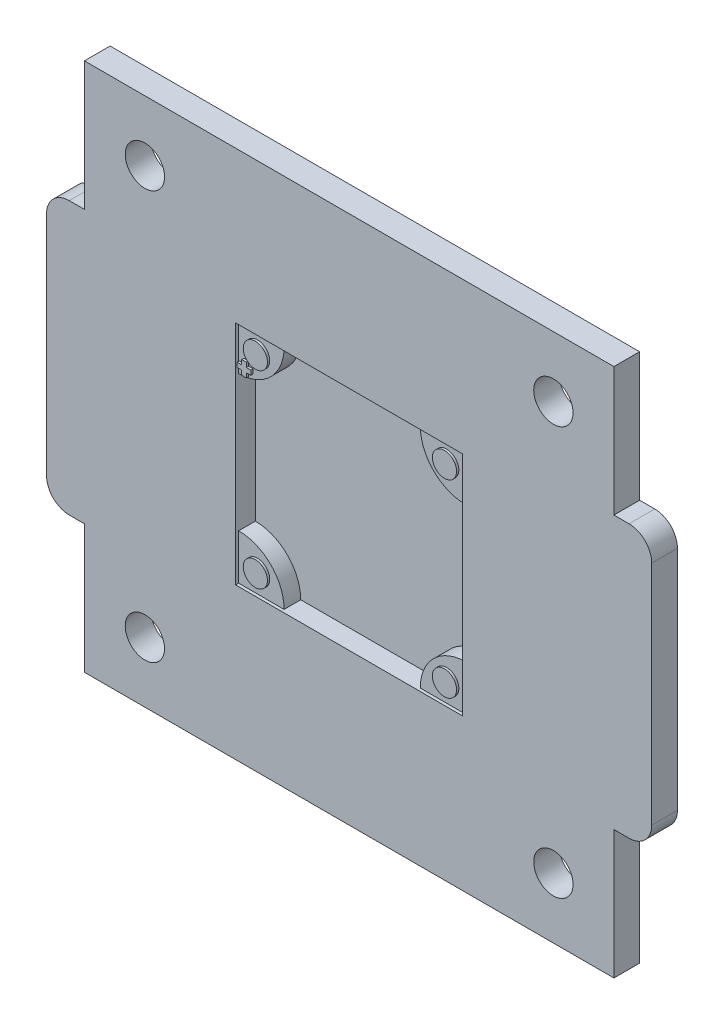
from build123d import *

# Parameters (mm, degrees)
SKETCH_1_W          = 70
SKETCH_1_H          = 70
EXTRUDE_1_DEPTH     = 3.4
SKETCH_2_W          = 30
SKETCH_2_H          = 30
CUT_EXTRUDE_1_DEPTH = 2.6
SKETCH_3_R          = 2.6
CUT_EXTRUDE_2_DEPTH = 4.4
EXTRUDE_2_DEPTH     = 3
SKETCH_6_R          = 1.6
EXTRUDE_3_DEPTH     = 0.3


with BuildPart() as part:
    # 草图1 → 凸台-拉伸1 (new body)
    with BuildSketch(Plane.XY):
        with BuildLine():
            Line((-2, 17), (0, 17))
            Line((0, 17), (0, 53))
            Line((0, 53), (-2, 53))
            ThreePointArc((-2, 53), (-4.121320344, 52.121320344), (-5, 50))
            Line((-5, 50), (-5, 20))
            ThreePointArc((-5, 20), (-4.121320344, 17.878679656), (-2, 17))
        make_face()
        with Locations((35, 35)):
            Rectangle(SKETCH_1_W, SKETCH_1_H)
        with BuildLine():
            Line((70, 53), (70, 17))
            Line((70, 17), (72, 17))
            ThreePointArc((72, 17), (74.121320344, 17.878679656), (75, 20))
            Line((75, 20), (75, 50))
            ThreePointArc((75, 50), (74.121320344, 52.121320344), (72, 53))
            Line((72, 53), (70, 53))
        make_face()
    extrude(amount=EXTRUDE_1_DEPTH)

    # 草图2 → 切除-拉伸1 (cut)
    with BuildSketch(Plane.XY.offset(3.4)):
        with Locations((35, 35)):
            Rectangle(SKETCH_2_W, SKETCH_2_H)
    extrude(amount=-CUT_EXTRUDE_1_DEPTH, mode=Mode.SUBTRACT)

    # 草图3 → 切除-拉伸2 (cut, through all)
    with BuildSketch(Plane.XY.offset(3.4)):
        with Locations((8, 62)):
            Circle(SKETCH_3_R)
        with Locations((62, 62)):
            Circle(SKETCH_3_R)
        with Locations((8, 8)):
            Circle(SKETCH_3_R)
        with Locations((62, 8)):
            Circle(SKETCH_3_R)
    extrude(amount=-CUT_EXTRUDE_2_DEPTH, mode=Mode.SUBTRACT)

    # 草图4 → 凸台-拉伸2 (add)
    with BuildSketch(Plane.XY):
        with BuildLine():
            Line((20, 44), (20, 50))
            Line((20, 50), (26, 50))
            ThreePointArc((26, 50), (24.242640687, 45.757359313), (20, 44))
        make_face()
        with BuildLine():
            Line((50, 44), (50, 50))
            Line((50, 50), (44, 50))
            ThreePointArc((44, 50), (45.757359313, 45.757359313), (50, 44))
        make_face()
        with BuildLine():
            Line((50, 20), (44, 20))
            ThreePointArc((44, 20), (45.757359313, 24.242640687), (50, 26))
            Line((50, 26), (50, 20))
        make_face()
        with BuildLine():
            Line((20, 26), (20, 20))
            Line((20, 20), (26, 20))
            ThreePointArc((26, 20), (24.242640687, 24.242640687), (20, 26))
        make_face()
    extrude(amount=EXTRUDE_2_DEPTH)

    # 草图6 → 凸台-拉伸3 (add)
    with BuildSketch(Plane.XY.offset(3)):
        with Locations((22.5, 47.5)):
            Circle(SKETCH_6_R)
        with Locations((47.5, 47.5)):
            Circle(SKETCH_6_R)
        with Locations((47.5, 22.5)):
            Circle(SKETCH_6_R)
        with Locations((22.5, 22.5)):
            Circle(SKETCH_6_R)
        Polygon((20.1, 45.5), (20.7, 45.5), (20.7, 46.1), (21.3, 46.1), (21.3, 45.5), (21.9, 45.5), (21.9, 44.9), (21.3, 44.9), (21.3, 44.3), (20.7, 44.3), (20.7, 44.9), (20.1, 44.9), align=None)
    extrude(amount=EXTRUDE_3_DEPTH)


solid = part.part
